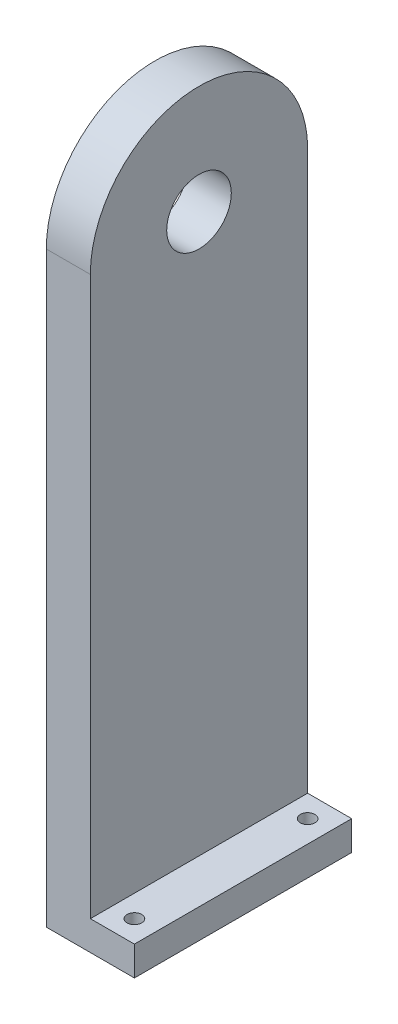
from build123d import *

# Parameters (mm, degrees)
BOSS_EXTRUDE1_DEPTH = 15
SKETCH2_W           = 15
SKETCH2_H           = 74
BOSS_EXTRUDE2_DEPTH = 10
SKETCH3_R           = 2.5
CUT_EXTRUDE1_DEPTH  = 10
SKETCH4_R           = 11
CUT_EXTRUDE2_DEPTH  = 31


with BuildPart() as part:
    # Sketch1 → Boss-Extrude1 (new body)
    with BuildSketch(Plane(origin=(0, 0, 0), x_dir=(0, 0, -1), z_dir=(1, 0, 0))):
        with BuildLine():
            Line((-37, 0), (-37, -200))
            Line((-37, -200), (37, -200))
            Line((37, -200), (37, 0))
            ThreePointArc((37, 0), (0, 37), (-37, 0))
        make_face()
    extrude(amount=BOSS_EXTRUDE1_DEPTH)

    # Sketch2 → Boss-Extrude2 (add)
    with BuildSketch(Plane.XZ.offset(200)):
        with Locations((22.5, 0)):
            Rectangle(SKETCH2_W, SKETCH2_H)
    extrude(amount=-BOSS_EXTRUDE2_DEPTH)

    # Sketch3 → Cut-Extrude1 (cut)
    with BuildSketch(Plane.XZ.offset(200)):
        with Locations((22.5, 29.5)):
            Circle(SKETCH3_R)
        with Locations((22.5, -29.5)):
            Circle(SKETCH3_R)
    extrude(amount=-CUT_EXTRUDE1_DEPTH, mode=Mode.SUBTRACT)

    # Sketch4 → Cut-Extrude2 (cut, through all)
    with BuildSketch(Plane.ZY):
        Circle(SKETCH4_R)
    extrude(amount=-CUT_EXTRUDE2_DEPTH, mode=Mode.SUBTRACT)


solid = part.part
